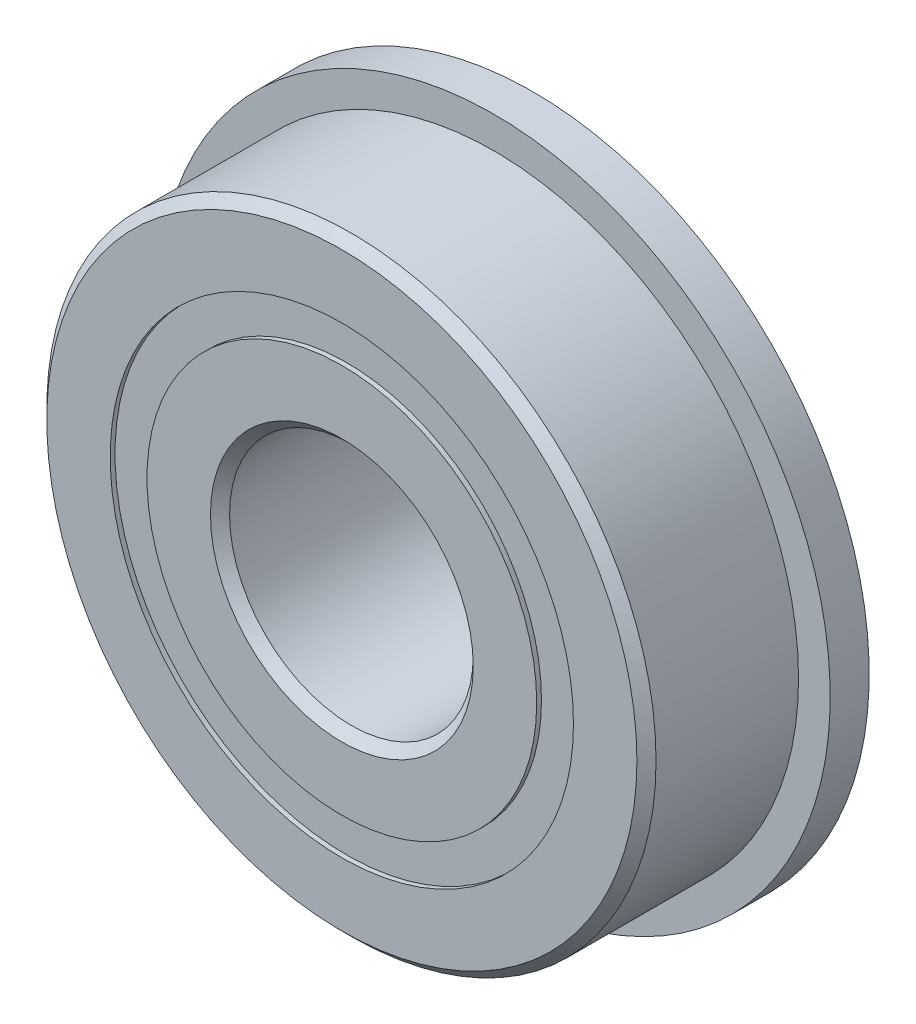
from build123d import *

# Parameters (mm, degrees)
CIRPATTERN1_COUNT = 14
SKETCH5_W         = 1.15919535
SKETCH5_H         = 0.957942858
SKETCH6_W         = 1.016
SKETCH6_H         = 2.727778571


with BuildPart() as part:
    # Sketch → Revolve1 (revolve)
    with BuildSketch(Plane(origin=(0, 0, 0), x_dir=(0, 0, -1), z_dir=(1, 0, 0))):
        with BuildLine():
            Line((2.24028, 7.9375), (-2.24028, 7.9375))
            Line((-2.24028, 7.9375), (-2.4892, 7.68858))
            Line((-2.4892, 7.68858), (-2.4892, 6.035221429))
            Line((-2.4892, 6.035221429), (-1.106311111, 6.035221429))
            ThreePointArc((-1.106311111, 6.035221429), (0, 6.76179465), (1.106311111, 6.035221429))
            Line((1.106311111, 6.035221429), (2.4892, 6.035221429))
            Line((2.4892, 6.035221429), (2.4892, 7.68858))
            Line((2.4892, 7.68858), (2.24028, 7.9375))
        make_face()
    revolve(axis=Axis((0, 0, 2.4892), (0, 0, -1)))

    # Sketch6 → Revolve6 (revolve)
    with BuildSketch(Plane(origin=(0, 0, 0), x_dir=(0, 0, -1), z_dir=(1, 0, 0))):
        with Locations((1.9812, 7.399110715)):
            Rectangle(SKETCH6_W, SKETCH6_H)
    revolve(axis=Axis((0, 0, -2.4892), (0, 0, 1)))


with BuildPart() as body_2:
    # Sketch3 → Revolve3 (revolve)
    with BuildSketch(Plane(origin=(0, 0, 0), x_dir=(0, 0, -1), z_dir=(1, 0, 0))):
        with BuildLine():
            Line((-2.4892, 5.077278571), (-1.106311111, 5.077278571))
            ThreePointArc((-1.106311111, 5.077278571), (0, 4.35070535), (1.106311111, 5.077278571))
            Line((1.106311111, 5.077278571), (2.4892, 5.077278571))
            Line((2.4892, 5.077278571), (2.4892, 3.42392))
            Line((2.4892, 3.42392), (2.24028, 3.175))
            Line((2.24028, 3.175), (-2.24028, 3.175))
            Line((-2.24028, 3.175), (-2.4892, 3.42392))
            Line((-2.4892, 3.42392), (-2.4892, 5.077278571))
        make_face()
    revolve(axis=Axis((0, 0, 2.4892), (0, 0, -1)))


with BuildPart() as body_3:
    # Sketch4 → Revolve4 (revolve)
    with BuildSketch(Plane(origin=(0, 0, 0), x_dir=(0, 0, -1), z_dir=(1, 0, 0))):
        with BuildLine():
            Line((-1.20554465, 5.55625), (1.20554465, 5.55625))
            ThreePointArc((1.20554465, 5.55625), (0, 6.76179465), (-1.20554465, 5.55625))
        make_face()
    revolve(axis=Axis((0, 5.55625, 1.20554465), (0, 0, -1)))


with BuildPart() as cirpattern1_1:
    # CirPattern1: pattern copy
    add(body_3.part.rotate(Axis((0, 0, -2.4892), (0, 0, 1)), 1 * 360 / CIRPATTERN1_COUNT))


with BuildPart() as cirpattern1_2:
    # CirPattern1: pattern copy
    add(body_3.part.rotate(Axis((0, 0, -2.4892), (0, 0, 1)), 2 * 360 / CIRPATTERN1_COUNT))


with BuildPart() as cirpattern1_3:
    # CirPattern1: pattern copy
    add(body_3.part.rotate(Axis((0, 0, -2.4892), (0, 0, 1)), 3 * 360 / CIRPATTERN1_COUNT))


with BuildPart() as cirpattern1_4:
    # CirPattern1: pattern copy
    add(body_3.part.rotate(Axis((0, 0, -2.4892), (0, 0, 1)), 4 * 360 / CIRPATTERN1_COUNT))


with BuildPart() as cirpattern1_5:
    # CirPattern1: pattern copy
    add(body_3.part.rotate(Axis((0, 0, -2.4892), (0, 0, 1)), 5 * 360 / CIRPATTERN1_COUNT))


with BuildPart() as cirpattern1_6:
    # CirPattern1: pattern copy
    add(body_3.part.rotate(Axis((0, 0, -2.4892), (0, 0, 1)), 6 * 360 / CIRPATTERN1_COUNT))


with BuildPart() as cirpattern1_7:
    # CirPattern1: pattern copy
    add(body_3.part.rotate(Axis((0, 0, -2.4892), (0, 0, 1)), 7 * 360 / CIRPATTERN1_COUNT))


with BuildPart() as cirpattern1_8:
    # CirPattern1: pattern copy
    add(body_3.part.rotate(Axis((0, 0, -2.4892), (0, 0, 1)), 8 * 360 / CIRPATTERN1_COUNT))


with BuildPart() as cirpattern1_9:
    # CirPattern1: pattern copy
    add(body_3.part.rotate(Axis((0, 0, -2.4892), (0, 0, 1)), 9 * 360 / CIRPATTERN1_COUNT))


with BuildPart() as cirpattern1_10:
    # CirPattern1: pattern copy
    add(body_3.part.rotate(Axis((0, 0, -2.4892), (0, 0, 1)), 10 * 360 / CIRPATTERN1_COUNT))


with BuildPart() as cirpattern1_11:
    # CirPattern1: pattern copy
    add(body_3.part.rotate(Axis((0, 0, -2.4892), (0, 0, 1)), 11 * 360 / CIRPATTERN1_COUNT))


with BuildPart() as cirpattern1_12:
    # CirPattern1: pattern copy
    add(body_3.part.rotate(Axis((0, 0, -2.4892), (0, 0, 1)), 12 * 360 / CIRPATTERN1_COUNT))


with BuildPart() as cirpattern1_13:
    # CirPattern1: pattern copy
    add(body_3.part.rotate(Axis((0, 0, -2.4892), (0, 0, 1)), 13 * 360 / CIRPATTERN1_COUNT))


with BuildPart() as body_17:
    # Sketch5 → Revolve5 (revolve)
    with BuildSketch(Plane(origin=(0, 0, 0), x_dir=(0, 0, -1), z_dir=(1, 0, 0))):
        with Locations((-1.785142325, 5.55625)):
            Rectangle(SKETCH5_W, SKETCH5_H)
        with Locations((1.785142325, 5.55625)):
            Rectangle(SKETCH5_W, SKETCH5_H)
    revolve(axis=Axis((0, 0, 2.4892), (0, 0, -1)))


solid = Compound([part.part, body_2.part, body_3.part, cirpattern1_1.part, cirpattern1_2.part, cirpattern1_3.part, cirpattern1_4.part, cirpattern1_5.part, cirpattern1_6.part, cirpattern1_7.part, cirpattern1_8.part, cirpattern1_9.part, cirpattern1_10.part, cirpattern1_11.part, cirpattern1_12.part, cirpattern1_13.part, body_17.part])
